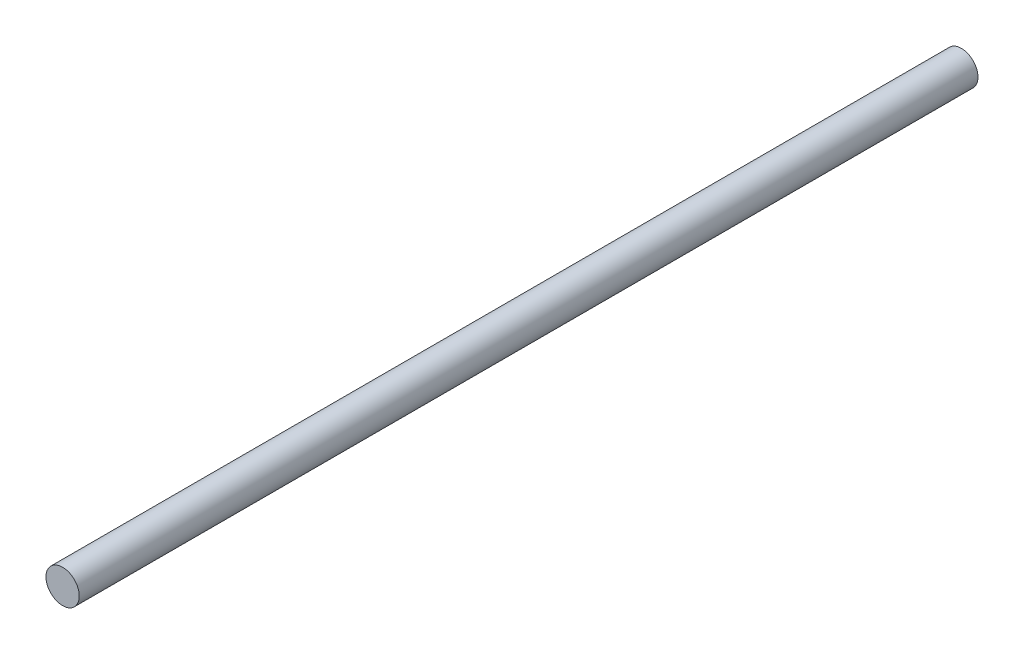
from build123d import *

# Parameters (mm, degrees)
SKETCH1_R           = 6.35
BOSS_EXTRUDE1_DEPTH = 342.9


with BuildPart() as part:
    # Sketch1 → Boss-Extrude1 (new body)
    with BuildSketch(Plane.XY):
        Circle(SKETCH1_R)
    extrude(amount=BOSS_EXTRUDE1_DEPTH)


solid = part.part
